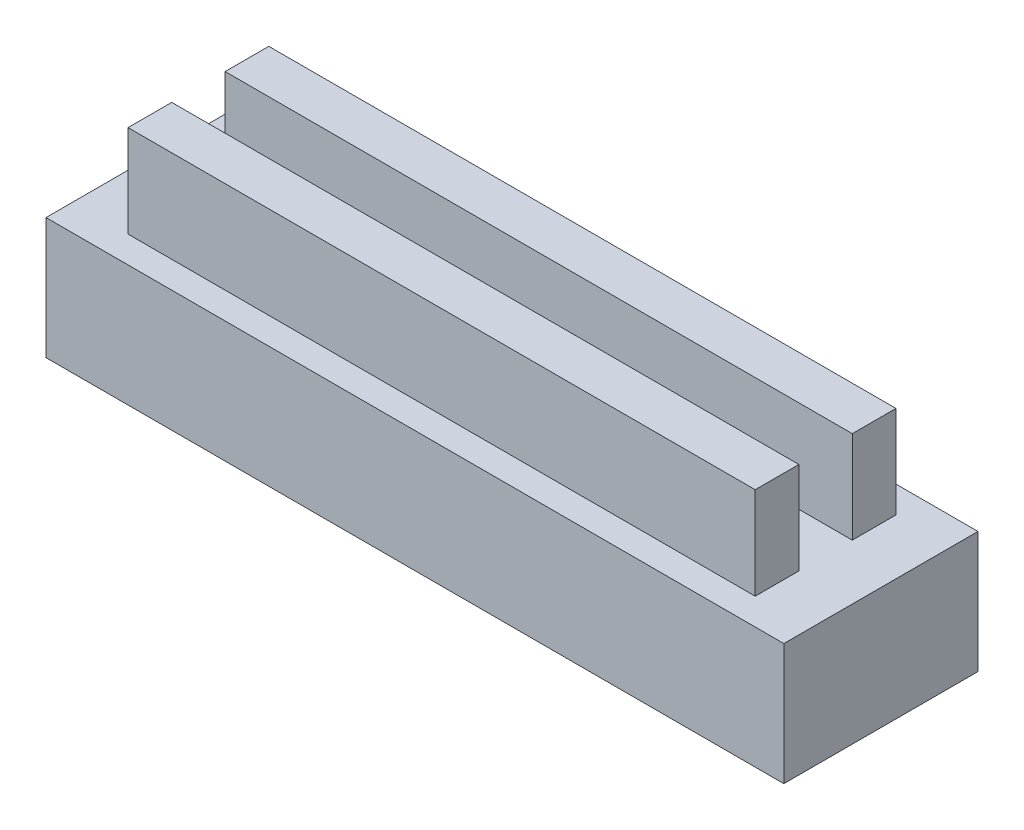
from build123d import *

# Parameters (mm, degrees)
SKETCH1_W           = 15.2
SKETCH1_H           = 4
BOSS_EXTRUDE1_DEPTH = 2.5
SKETCH2_W           = 12.92
SKETCH2_H           = 0.9
BOSS_EXTRUDE2_DEPTH = 1.9


with BuildPart() as part:
    # Sketch1 → Boss-Extrude1 (new body)
    with BuildSketch(Plane(origin=(0, 0, 0), x_dir=(1, 0, 0), z_dir=(0, 1, 0))):
        Rectangle(SKETCH1_W, SKETCH1_H)
    extrude(amount=BOSS_EXTRUDE1_DEPTH)

    # Sketch2 → Boss-Extrude2 (add)
    with BuildSketch(Plane(origin=(0, 2.5, 0), x_dir=(1, 0, 0), z_dir=(0, 1, 0))):
        with Locations((0, -1)):
            Rectangle(SKETCH2_W, SKETCH2_H)
        with Locations((0, 1)):
            Rectangle(SKETCH2_W, SKETCH2_H)
    extrude(amount=BOSS_EXTRUDE2_DEPTH)


solid = part.part
